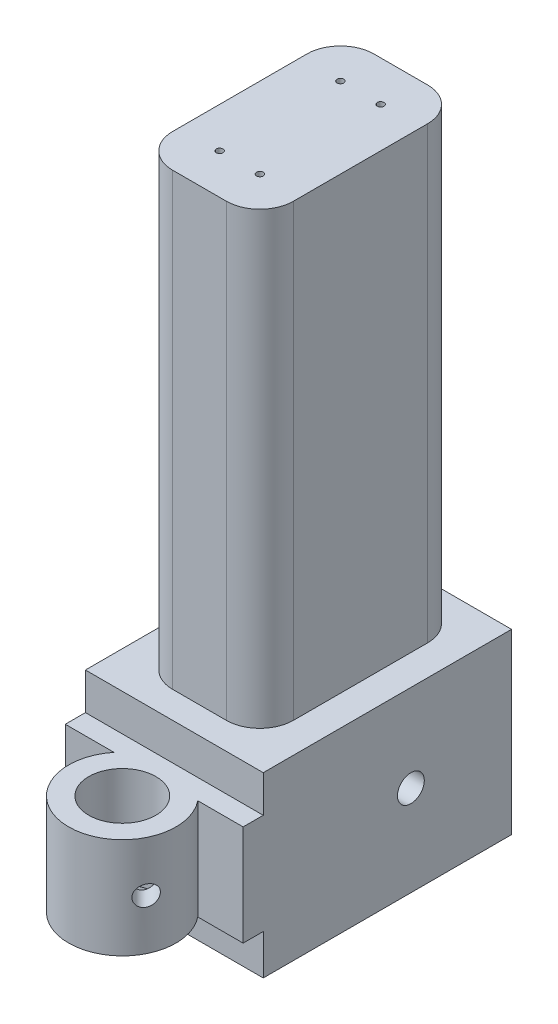
from build123d import *

# Parameters (mm, degrees)
ESQUISSE1_W                   = 26.5
ESQUISSE1_H                   = 26.5
BOSS_EXTRU_1_DEPTH            = 40
ESQUISSE2_W                   = 20.5
ESQUISSE2_H                   = 20.5
ENL_V_MAT_EXTRU_1_DEPTH       = 21
ESQUISSE4_R                   = 8
ESQUISSE4_R_2                 = 5
BOSS_EXTRU_3_DEPTH            = 7.5
BOSS_EXTRU_4_START            = -7.5
ESQUISSE4_4_R                 = 8
ESQUISSE4_4_R_2               = 5
BOSS_EXTRU_4_DEPTH            = 7.5
ESQUISSE8_W                   = 26.5
ESQUISSE8_H                   = 3
ENL_V_MAT_EXTRU_4_DEPTH       = 6
ESQUISSE12_W                  = 18
ESQUISSE12_H                  = 30
BOSS_EXTRU_5_DEPTH            = 67
CONG_1_R                      = 5
CONG_2_R                      = 5
CONG_3_R                      = 5
CONG_4_R                      = 5
ENL_V_MAT_EXTRU_7_REACH       = 95.245
ESQUISSE17_R                  = 1.5
ENL_V_MAT_EXTRU_8_REACH       = 95.137
ESQUISSE18_R                  = 1.5
ESQUISSE13_R                  = 0.5
ENL_V_MAT_EXTRU_9_DEPTH       = 5
ENL_V_MAT_EXTRU_10_DEPTH      = 99.429363265
ENL_V_MAT_EXTRU_10_DEPTH_BACK = 99.429363265
ESQUISSE19_R                  = 2
ENL_V_MAT_EXTRU_11_REACH      = 110.36
ESQUISSE20_R                  = 2
ESQUISSE9_W                   = 26.5
ESQUISSE9_H                   = 3
ENL_V_MAT_EXTRU_13_DEPTH      = 5.5


with BuildPart() as part:
    # Esquisse1 → Boss.-Extru.1 (new body)
    with BuildSketch(Plane.XY):
        with Locations((0.553632827, -1.655537459)):
            Rectangle(ESQUISSE1_W, ESQUISSE1_H)
    extrude(amount=BOSS_EXTRU_1_DEPTH)

    # Esquisse2 → Enlèv. mat.-Extru.1 (cut)
    with BuildSketch(Plane(origin=(0, 0, 0), x_dir=(-1, 0, 0), z_dir=(0, 0, -1))):
        with Locations((-0.553632827, -1.655537459)):
            Rectangle(ESQUISSE2_W, ESQUISSE2_H)
    extrude(amount=-ENL_V_MAT_EXTRU_1_DEPTH, mode=Mode.SUBTRACT)

    # Esquisse4 → Boss.-Extru.3 (add)
    with BuildSketch(Plane(origin=(0, -1.405537459, 0), x_dir=(-1, 0, 0), z_dir=(0, -1, 0))):
        with Locations((-0.803632827, -45)):
            Circle(ESQUISSE4_R)
        with Locations((-0.803632827, -45)):
            Circle(ESQUISSE4_R_2, mode=Mode.SUBTRACT)
    extrude(amount=BOSS_EXTRU_3_DEPTH)

    # Esquisse4_4 → Boss.-Extru.4 (add)
    with BuildSketch(Plane(origin=(0, -1.405537459, 0), x_dir=(-1, 0, 0), z_dir=(0, -1, 0)).offset(BOSS_EXTRU_4_START)):
        with Locations((-0.803632827, -45)):
            Circle(ESQUISSE4_4_R)
        with Locations((-0.803632827, -45)):
            Circle(ESQUISSE4_4_R_2, mode=Mode.SUBTRACT)
    extrude(amount=BOSS_EXTRU_4_DEPTH)

    # Esquisse8 → Enlèv. mat.-Extru.4 (cut)
    with BuildSketch(Plane.XZ.offset(14.905537459)):
        with Locations((0.553632827, 38.5)):
            Rectangle(ESQUISSE8_W, ESQUISSE8_H)
    extrude(amount=-ENL_V_MAT_EXTRU_4_DEPTH, mode=Mode.SUBTRACT)

    # Esquisse12 → Boss.-Extru.5 (add)
    with BuildSketch(Plane(origin=(0, 11.594462541, 0), x_dir=(1, 0, 0), z_dir=(0, 1, 0))):
        with Locations((0.303632827, -18)):
            Rectangle(ESQUISSE12_W, ESQUISSE12_H)
    extrude(amount=BOSS_EXTRU_5_DEPTH)

    # Congé1
    cong_1_edges = [part.edges().sort_by_distance(p)[0] for p in [
        (9.303632827, 45.094462541, 33),
    ]]
    fillet(cong_1_edges, radius=CONG_1_R)

    # Congé2
    cong_2_edges = [part.edges().sort_by_distance(p)[0] for p in [
        (-8.696367173, 45.094462541, 33),
    ]]
    fillet(cong_2_edges, radius=CONG_2_R)

    # Congé3
    cong_3_edges = [part.edges().sort_by_distance(p)[0] for p in [
        (-8.696367173, 45.094462541, 3),
    ]]
    fillet(cong_3_edges, radius=CONG_3_R)

    # Congé4
    cong_4_edges = [part.edges().sort_by_distance(p)[0] for p in [
        (9.303632827, 45.094462541, 3),
    ]]
    fillet(cong_4_edges, radius=CONG_4_R)

    # Esquisse17 → Enlèv. mat.-Extru.7 (cut, up to next)
    with BuildSketch(Plane(origin=(28.558670663, 0, 28.558670663), x_dir=(0.7071067811865476, 0, -0.7071067811865476), z_dir=(0.7071067811865476, 0, 0.7071067811865476)), mode=Mode.PRIVATE) as enl_v_mat_extru_7_sk1:
        with Locations((-28.738974236, -1.405537459)):
            Circle(ESQUISSE17_R)
    enl_v_mat_extru_7_tool1 = extrude(enl_v_mat_extru_7_sk1.sketch, amount=-ENL_V_MAT_EXTRU_7_REACH, mode=Mode.PRIVATE) & part.part
    add(enl_v_mat_extru_7_tool1.solids().sort_by_distance((8.237147, -1.405537, 48.880194))[0], mode=Mode.SUBTRACT)

    # Esquisse18 → Enlèv. mat.-Extru.8 (cut, up to next)
    with BuildSketch(Plane(origin=(-27.755037836, 0, 27.755037836), x_dir=(0.7071067811865476, 0, 0.7071067811865476), z_dir=(-0.7071067811865476, 0, 0.7071067811865476)), mode=Mode.PRIVATE) as enl_v_mat_extru_8_sk1:
        with Locations((29.875394998, -1.405537459)):
            Circle(ESQUISSE18_R)
    enl_v_mat_extru_8_tool1 = extrude(enl_v_mat_extru_8_sk1.sketch, amount=-ENL_V_MAT_EXTRU_8_REACH, mode=Mode.PRIVATE) & part.part
    add(enl_v_mat_extru_8_tool1.solids().sort_by_distance((-6.629943, -1.405537, 48.880132))[0], mode=Mode.SUBTRACT)

    # Esquisse13 → Enlèv. mat.-Extru.9 (cut)
    with BuildSketch(Plane(origin=(0, 78.594462541, 0), x_dir=(1, 0, 0), z_dir=(0, 1, 0))):
        with Locations((3.303632827, -9)):
            Circle(ESQUISSE13_R)
        with Locations((-2.696367173, -9)):
            Circle(ESQUISSE13_R)
        with Locations((3.303632827, -27)):
            Circle(ESQUISSE13_R)
        with Locations((-2.696367173, -27)):
            Circle(ESQUISSE13_R)
    extrude(amount=-ENL_V_MAT_EXTRU_9_DEPTH, mode=Mode.SUBTRACT)

    # Esquisse19 → Enlèv. mat.-Extru.10 (cut, two sides: drawn at the far end of the back side and taken through both)
    with BuildSketch(Plane.ZY.offset(12.696367173).offset(-ENL_V_MAT_EXTRU_10_DEPTH_BACK)):
        with Locations((15, -1.405537459)):
            Circle(ESQUISSE19_R)
    extrude(amount=ENL_V_MAT_EXTRU_10_DEPTH + ENL_V_MAT_EXTRU_10_DEPTH_BACK, mode=Mode.SUBTRACT)

    # Esquisse20 → Enlèv. mat.-Extru.11 (cut, up to next)
    with BuildSketch(Plane.XZ.offset(14.905537459), mode=Mode.PRIVATE) as enl_v_mat_extru_11_sk1:
        with Locations((0.303632827, 15)):
            Circle(ESQUISSE20_R)
    enl_v_mat_extru_11_tool1 = extrude(enl_v_mat_extru_11_sk1.sketch, amount=-ENL_V_MAT_EXTRU_11_REACH, mode=Mode.PRIVATE) & part.part
    add(enl_v_mat_extru_11_tool1.solids().sort_by_distance((0.303633, -14.905537, 15))[0], mode=Mode.SUBTRACT)

    # Esquisse9 → Enlèv. mat.-Extru.13 (cut)
    with BuildSketch(Plane(origin=(0, 11.594462541, 0), x_dir=(1, 0, 0), z_dir=(0, 1, 0))):
        with Locations((0.553632827, -38.5)):
            Rectangle(ESQUISSE9_W, ESQUISSE9_H)
    extrude(amount=-ENL_V_MAT_EXTRU_13_DEPTH, mode=Mode.SUBTRACT)


solid = part.part
